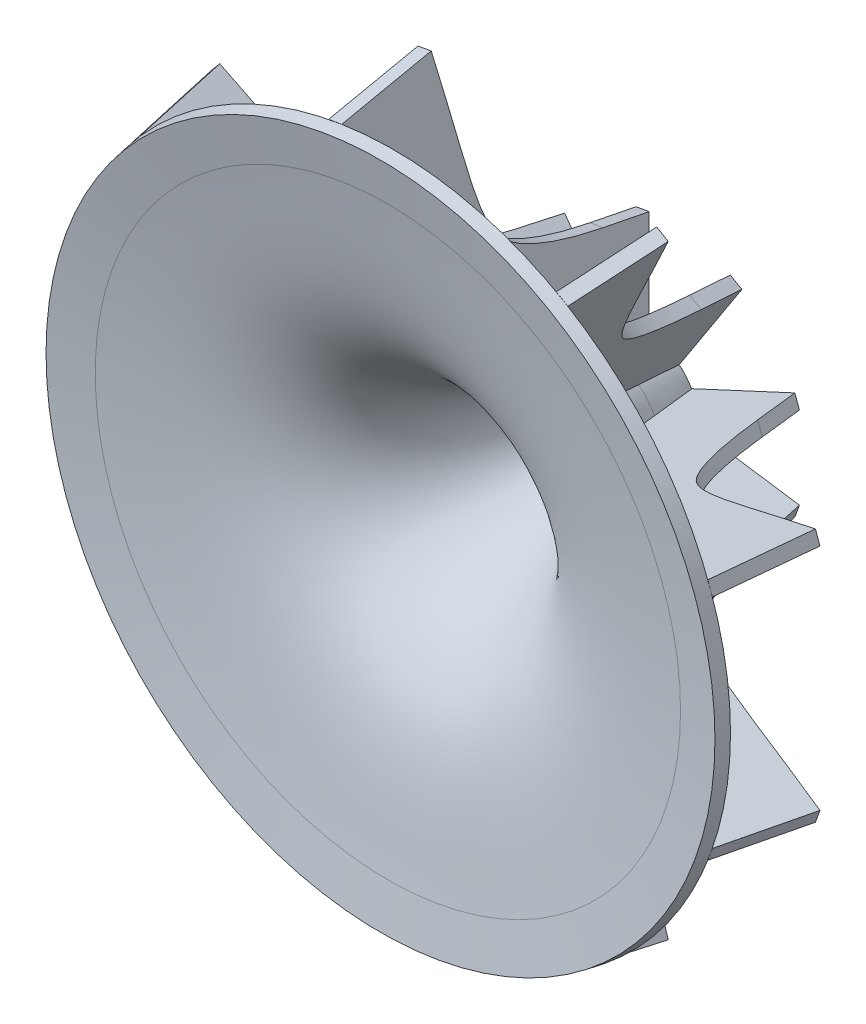
from build123d import *

# Parameters (mm, degrees)
BLADE_DEPTH       = 0.5
CIRPATTERN5_COUNT = 9


with BuildPart() as part:
    # Sketch_of_Hub → Hub (revolve)
    with BuildSketch(Plane(origin=(0, 0, 0), x_dir=(1, 0, 0), z_dir=(0, 1, 0))):
        with BuildLine():
            Line((-25, 0), (-21.875, 0.551021815))
            add(Edge.make_bspline(
                [(-21.875, 0.551021815), (-12.655262266, 2.176710332), (-5.675135971, 1.992909092), (-3.087756602, 16.666666667)],
                knots=[0, 0, 0, 0, 1, 1, 1, 1], degree=3))
            Line((-3.087756602, 16.666666667), (-2.5, 20))
            Line((-2.5, 20), (-3.484807753, 20.173648178))
            Line((-3.484807753, 20.173648178), (-4.072564355, 16.840314844))
            add(Edge.make_bspline(
                [(-22.048648178, 1.535829568), (-21.478094224, 1.636433624), (-20.317964448, 1.829846586), (-18.133137488, 2.182078373), (-15.573097923, 2.634890711), (-12.841426017, 3.375790026), (-10.465375823, 4.478355969), (-8.417885764, 6.109004535), (-6.938701311, 8.105088767), (-5.897979088, 10.21708179), (-5.196580182, 12.084345826), (-4.682308699, 13.905719087), (-4.319333433, 15.516895238), (-4.149347465, 16.40485619), (-4.072564355, 16.840314844)],
                knots=[0, 0, 0, 0, 0.0625, 0.125, 0.25, 0.375, 0.5, 0.625, 0.75, 0.8125, 0.875, 0.9375, 0.96875, 1, 1, 1, 1], degree=3))
            Line((-22.048648178, 1.535829568), (-25.173648178, 0.984807753))
            Line((-25.173648178, 0.984807753), (-25, 0))
        make_face()
    revolve(axis=Axis((0, 0, 11.410665709), (0, 0, -1)))


with BuildPart() as body_2:
    # Sketch9 → Blade (new body, symmetric)
    with BuildSketch(Plane(origin=(0, 0, 0), x_dir=(1, 0, 0), z_dir=(0, 1, 0))):
        with BuildLine():
            Line((-10.378462024, 21.389185421), (-10.966218626, 18.055852088))
            add(Edge.make_bspline(
                [(-10.966218626, 18.055852088), (-11.030806768, 17.689554534), (-11.175810218, 16.93293623), (-11.468615135, 15.635689405), (-11.866926993, 14.233267736), (-12.34667485, 12.968667896), (-12.959130247, 11.742656166), (-13.569357152, 10.977560712), (-14.123332094, 10.531724998), (-15.134839985, 10.023561208), (-16.688956317, 9.584048646), (-18.359611032, 9.25142554), (-19.810816671, 9.001980231), (-21.428121028, 8.741362776), (-22.666214106, 8.534922315), (-23.264185421, 8.429483839)],
                knots=[0, 0, 0, 0, 0.03125, 0.0625, 0.125, 0.1875, 0.25, 0.375, 0.5, 0.625, 0.75, 0.8125, 0.875, 0.9375, 1, 1, 1, 1], degree=3))
            Line((-23.264185421, 8.429483839), (-26.389185421, 7.878462024))
            Line((-26.389185421, 7.878462024), (-25.173648178, 0.984807753))
            Line((-25.173648178, 0.984807753), (-22.048648178, 1.535829568))
            add(Edge.make_bspline(
                [(-4.072564355, 16.840314844), (-4.149347465, 16.40485619), (-4.319333433, 15.516895238), (-4.682308699, 13.905719087), (-5.196580182, 12.084345826), (-5.897979088, 10.21708179), (-6.938701311, 8.105088767), (-8.417885764, 6.109004535), (-10.465375823, 4.478355969), (-12.841426017, 3.375790026), (-15.573097923, 2.634890711), (-18.133137488, 2.182078373), (-20.317964448, 1.829846586), (-21.478094224, 1.636433624), (-22.048648178, 1.535829568)],
                knots=[0, 0, 0, 0, 0.03125, 0.0625, 0.125, 0.1875, 0.25, 0.375, 0.5, 0.625, 0.75, 0.875, 0.9375, 1, 1, 1, 1], degree=3))
            Line((-4.072564355, 16.840314844), (-3.484807753, 20.173648178))
            Line((-3.484807753, 20.173648178), (-10.378462024, 21.389185421))
        make_face()
    extrude(amount=BLADE_DEPTH, both=True)


with BuildPart() as cirpattern5_1:
    # CirPattern5: pattern copy
    add(body_2.part.rotate(Axis((0, 0, -20.173648178), (0, 0, 1)), 1 * 360 / CIRPATTERN5_COUNT))


with BuildPart() as cirpattern5_2:
    # CirPattern5: pattern copy
    add(body_2.part.rotate(Axis((0, 0, -20.173648178), (0, 0, 1)), 2 * 360 / CIRPATTERN5_COUNT))


with BuildPart() as cirpattern5_3:
    # CirPattern5: pattern copy
    add(body_2.part.rotate(Axis((0, 0, -20.173648178), (0, 0, 1)), 3 * 360 / CIRPATTERN5_COUNT))


with BuildPart() as cirpattern5_4:
    # CirPattern5: pattern copy
    add(body_2.part.rotate(Axis((0, 0, -20.173648178), (0, 0, 1)), 4 * 360 / CIRPATTERN5_COUNT))


with BuildPart() as cirpattern5_5:
    # CirPattern5: pattern copy
    add(body_2.part.rotate(Axis((0, 0, -20.173648178), (0, 0, 1)), 5 * 360 / CIRPATTERN5_COUNT))


with BuildPart() as cirpattern5_6:
    # CirPattern5: pattern copy
    add(body_2.part.rotate(Axis((0, 0, -20.173648178), (0, 0, 1)), 6 * 360 / CIRPATTERN5_COUNT))


with BuildPart() as cirpattern5_7:
    # CirPattern5: pattern copy
    add(body_2.part.rotate(Axis((0, 0, -20.173648178), (0, 0, 1)), 7 * 360 / CIRPATTERN5_COUNT))


with BuildPart() as cirpattern5_8:
    # CirPattern5: pattern copy
    add(body_2.part.rotate(Axis((0, 0, -20.173648178), (0, 0, 1)), 8 * 360 / CIRPATTERN5_COUNT))


solid = Compound([part.part, body_2.part, cirpattern5_1.part, cirpattern5_2.part, cirpattern5_3.part, cirpattern5_4.part, cirpattern5_5.part, cirpattern5_6.part, cirpattern5_7.part, cirpattern5_8.part])
